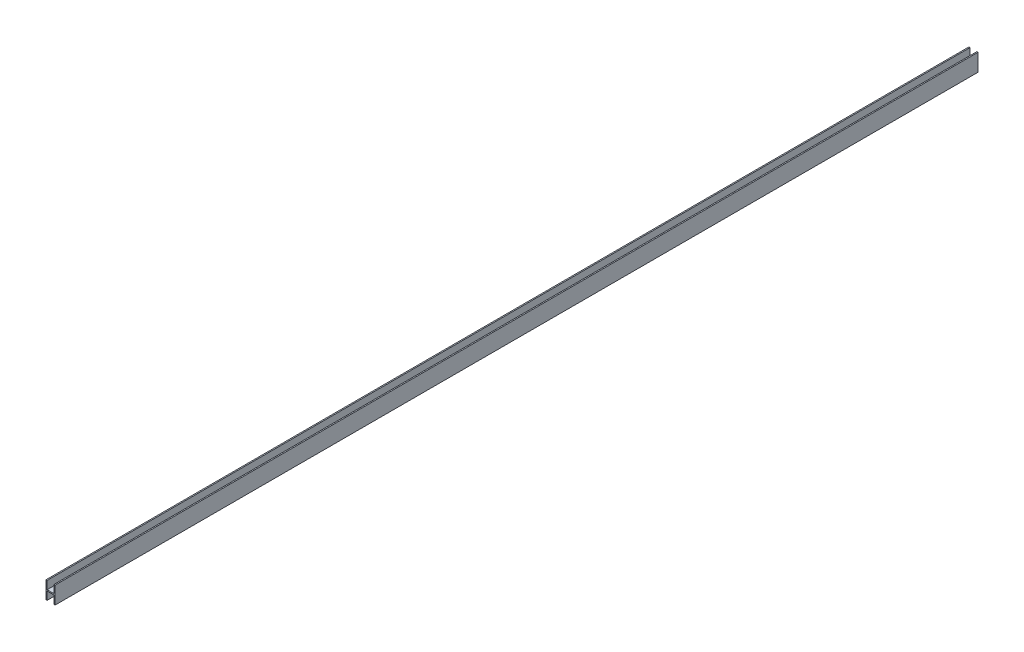
from build123d import *

# Parameters (mm, degrees)
SKETCH_1_W          = 8
SKETCH_1_H          = 15
EXTRUDE_1_DEPTH     = 800
SKETCH_2_W          = 6
SKETCH_2_H          = 14
CUT_EXTRUDE_1_DEPTH = 2400


with BuildPart() as part:
    # 草图1 → 凸台-拉伸1 (new body)
    with BuildSketch(Plane.XY):
        Rectangle(SKETCH_1_W, SKETCH_1_H)
    extrude(amount=EXTRUDE_1_DEPTH)

    # 草图2 → 切除-拉伸1 (cut)
    with BuildSketch(Plane(origin=(0, 0, 0), x_dir=(-1, 0, 0), z_dir=(0, 0, -1))):
        with Locations((0, -7.5)):
            Rectangle(SKETCH_2_W, SKETCH_2_H)
        with Locations((0, 7.5)):
            Rectangle(SKETCH_2_W, SKETCH_2_H)
    extrude(amount=-CUT_EXTRUDE_1_DEPTH, mode=Mode.SUBTRACT)


solid = part.part
